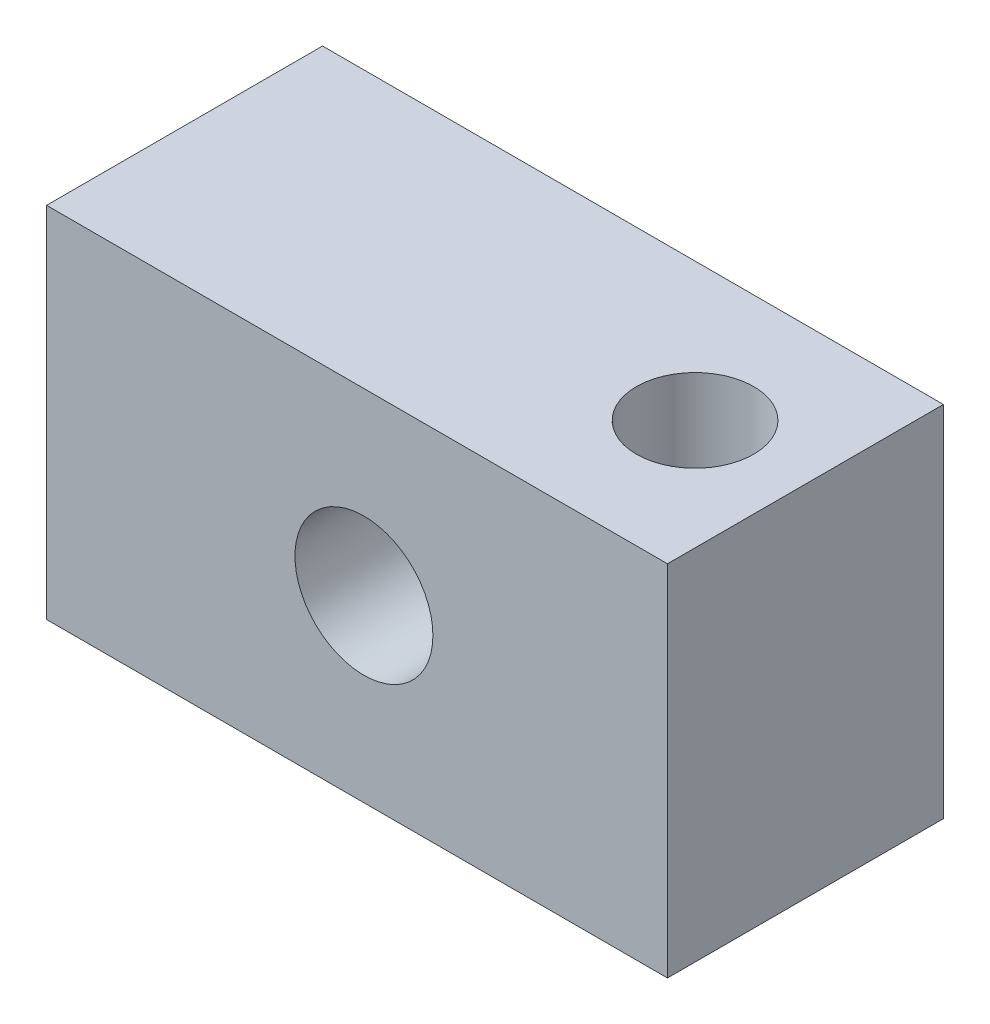
from build123d import *

# Parameters (mm, degrees)
ESQUISSE1_W                         = 45
ESQUISSE1_H                         = 26
BOSS_EXTRU_1_DEPTH                  = 20
ENL_V_MAT_EXTRU_1_REACH             = 22
ESQUISSE3_R                         = 5
ENL_V_MAT_EXTRU_1_DIRECTION_2_DEPTH = 1
TROU_TARAUD_M101_D                  = 8.5
TROU_TARAUD_M101_DEPTH              = 26


with BuildPart() as part:
    # Esquisse1 → Boss.-Extru.1 (new body)
    with BuildSketch(Plane.XY):
        with Locations((-22.5, 13)):
            Rectangle(ESQUISSE1_W, ESQUISSE1_H)
    extrude(amount=BOSS_EXTRU_1_DEPTH)

    # Esquisse3 → Enlèv. mat.-Extru.1 (cut, up to next)
    with BuildSketch(Plane(origin=(0, 0, 0), x_dir=(-1, 0, 0), z_dir=(0, 0, -1)), mode=Mode.PRIVATE) as enl_v_mat_extru_1_sk1:
        with Locations(Location((22, 13, 0), (0, 0, 180))):  # turned: the seam where the file's is
            Circle(ESQUISSE3_R)
    enl_v_mat_extru_1_tool1 = extrude(enl_v_mat_extru_1_sk1.sketch, amount=-ENL_V_MAT_EXTRU_1_REACH, mode=Mode.PRIVATE) & part.part
    add(enl_v_mat_extru_1_tool1.solids().sort_by_distance((-22, 13, 0))[0], mode=Mode.SUBTRACT)

    # Esquisse3 → Enlèv. mat.-Extru.1 direction 2 (cut)
    with BuildSketch(Plane(origin=(0, 0, 0), x_dir=(-1, 0, 0), z_dir=(0, 0, -1))):
        with Locations(Location((22, 13, 0), (0, 0, 180))):  # turned: the seam where the file's is
            Circle(ESQUISSE3_R)
    extrude(amount=ENL_V_MAT_EXTRU_1_DIRECTION_2_DEPTH, mode=Mode.SUBTRACT)

    # Trou taraudé M101
    with Locations(Plane(origin=(0, 26, 0), x_dir=(1, 0, 0), z_dir=(0, 1, 0))):
        with Locations((-8, -10)):
            Hole(TROU_TARAUD_M101_D / 2, depth=TROU_TARAUD_M101_DEPTH)


solid = part.part
